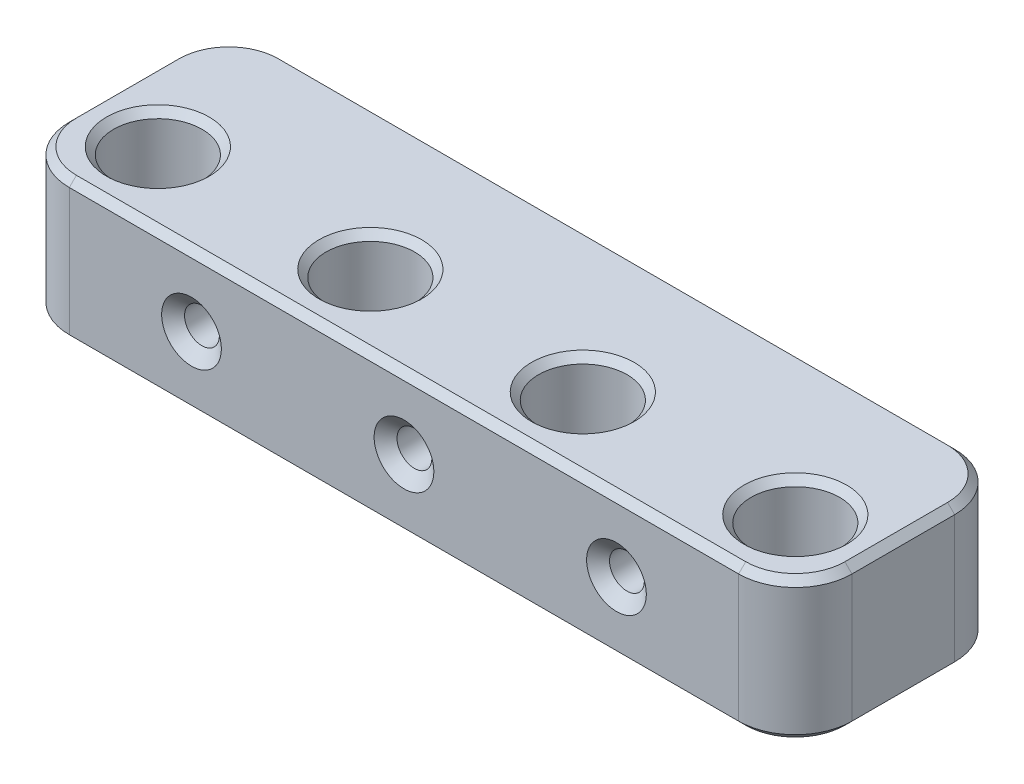
from build123d import *

# Parameters (mm, degrees)
SKETCH1_W                                         = 20.5
SKETCH1_H                                         = 20.5
SKETCH1_R                                         = 6.25
BOSS_EXTRUDE1_DEPTH                               = 20
SKETCH2_W                                         = 20.5
SKETCH2_H                                         = 20
BOSS_EXTRUDE2_DEPTH                               = 10
LPATTERN1_COUNT                                   = 4
LPATTERN1_PITCH                                   = 30
SKETCH3_W                                         = 9.5
SKETCH3_H                                         = 30.5
BOSS_EXTRUDE3_DEPTH                               = 20
CSK_FOR_8_FLAT_HEAD_MACHINE_SCREW_100_D           = 4.9149
CSK_FOR_8_FLAT_HEAD_MACHINE_SCREW_100_CSINK_D     = 8.4328
CSK_FOR_8_FLAT_HEAD_MACHINE_SCREW_100_CSINK_ANGLE = 100
FILLET1_R                                         = 8
CHAMFER1_SIZE                                     = 1


with BuildPart() as part:
    # Sketch1 → Boss-Extrude1 (new body)
    with BuildSketch(Plane(origin=(0, 0, 0), x_dir=(1, 0, 0), z_dir=(0, 1, 0))):
        Rectangle(SKETCH1_W, SKETCH1_H)
        Circle(SKETCH1_R, mode=Mode.SUBTRACT)
    extrude(amount=BOSS_EXTRUDE1_DEPTH)

    # Sketch2 → Boss-Extrude2 (add)
    with BuildSketch(Plane(origin=(0, 0, -10.25), x_dir=(-1, 0, 0), z_dir=(0, 0, -1))):
        with Locations((0, 10)):
            Rectangle(SKETCH2_W, SKETCH2_H)
    extrude(amount=BOSS_EXTRUDE2_DEPTH)


with BuildPart() as lpattern1_1:
    # LPattern1: pattern copy
    add(part.part.moved(Location(Vector(1, 0, 0) * (1 * LPATTERN1_PITCH))))


with BuildPart() as lpattern1_2:
    # LPattern1: pattern copy
    add(part.part.moved(Location(Vector(1, 0, 0) * (2 * LPATTERN1_PITCH))))


with BuildPart() as lpattern1_3:
    # LPattern1: pattern copy
    add(part.part.moved(Location(Vector(1, 0, 0) * (3 * LPATTERN1_PITCH))))


with BuildPart() as part_1:
    add(part.part)

    add(lpattern1_1.part)  # Boss-Extrude3 merges LPattern1_1

    add(lpattern1_2.part)  # Boss-Extrude3 merges LPattern1_2

    add(lpattern1_3.part)  # Boss-Extrude3 merges LPattern1_3
    # Sketch3 → Boss-Extrude3 (add)
    with BuildSketch(Plane(origin=(0, 20, 0), x_dir=(1, 0, 0), z_dir=(0, 1, 0))):
        with Locations((15, 5)):
            Rectangle(SKETCH3_W, SKETCH3_H)
        with Locations((45, 5)):
            Rectangle(SKETCH3_W, SKETCH3_H)
        with Locations((75, 5)):
            Rectangle(SKETCH3_W, SKETCH3_H)
    extrude(amount=-BOSS_EXTRUDE3_DEPTH)

    # CSK for #8 Flat Head Machine Screw (100)1 (through all)
    with Locations(Plane(origin=(15, 10, 10.25), x_dir=(1, 0, 0), z_dir=(0, 0, 1))):
        with Locations((0, 0), (30, 0), (60, 0)):
            CounterSinkHole(CSK_FOR_8_FLAT_HEAD_MACHINE_SCREW_100_D / 2, CSK_FOR_8_FLAT_HEAD_MACHINE_SCREW_100_CSINK_D / 2, counter_sink_angle=CSK_FOR_8_FLAT_HEAD_MACHINE_SCREW_100_CSINK_ANGLE)

    # Fillet1
    fillet1_edges = [part_1.edges().sort_by_distance(p)[0] for p in [
        (-10.25, 10, -20.25),
        (-10.25, 10, 10.25),
        (100.25, 10, 10.25),
        (100.25, 10, -20.25),
    ]]
    fillet(fillet1_edges, radius=FILLET1_R)

    # Chamfer1
    chamfer1_edges = [part_1.edges().sort_by_distance(p)[0] for p in [
        (45, 20, -20.25),
        (45, 0, -20.25),
        (45, 20, 10.25),
        (100.25, 20, -5),
        (-10.25, 20, -5),
        (-7.906854249, 20, 7.906854249),
        (97.906854249, 20, 7.906854249),
        (97.906854249, 20, -17.906854249),
        (-7.906854249, 20, -17.906854249),
        (-10.25, 0, -5),
        (-6.25, 0, 0),
        (100.25, 0, -5),
        (45, 0, 10.25),
        (-7.906854249, 0, 7.906854249),
        (-6.25, 20, 0),
        (97.906854249, 0, 7.906854249),
        (97.906854249, 0, -17.906854249),
        (-7.906854249, 0, -17.906854249),
        (23.75, 0, 0),
        (23.75, 20, 0),
        (53.75, 0, 0),
        (53.75, 20, 0),
        (83.75, 0, 0),
        (83.75, 20, 0),
    ]]
    chamfer(chamfer1_edges, length=CHAMFER1_SIZE)


solid = part_1.part
